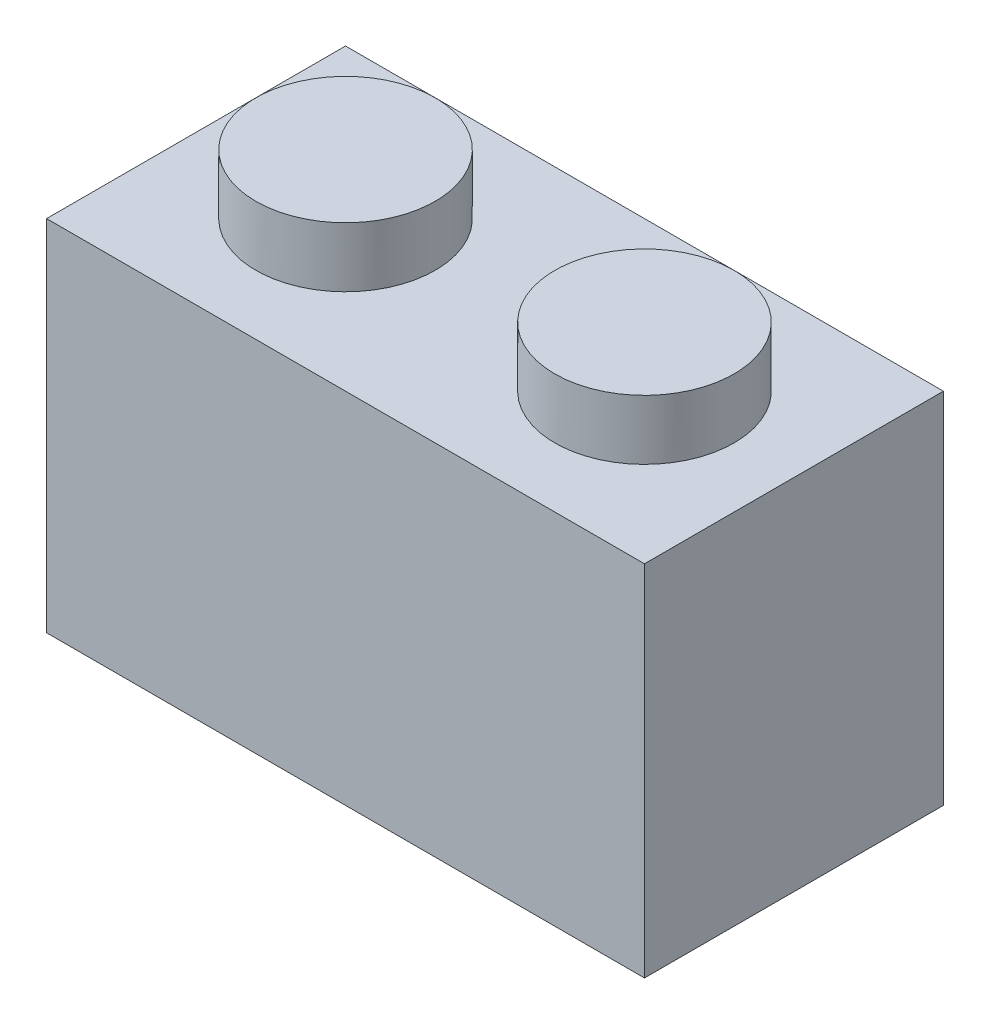
from build123d import *

# Parameters (mm, degrees)
SKETCH1_R             = 1.5
BOSS_EXTRUDE1_DEPTH   = 2
BOSS_EXTRUDE1_2_DEPTH = 2
SKETCH1_3_W           = 10
SKETCH1_3_H           = 5
BOSS_EXTRUDE2_DEPTH   = 1
SKETCH1_4_R           = 0.75
CUT_EXTRUDE1_DEPTH    = 1
SKETCH1_5_W           = 10
SKETCH1_5_H           = 5
SKETCH1_5_W_2         = 8
SKETCH1_5_H_2         = 3
SKETCH1_5_R           = 1
BOSS_EXTRUDE3_DEPTH   = 5


with BuildPart() as part:
    # Sketch1 → Boss-Extrude1 (new body)
    with BuildSketch(Plane(origin=(0, 0, 0), x_dir=(1, 0, 0), z_dir=(0, 1, 0))):
        with Locations((-2.5, 0)):
            Circle(SKETCH1_R)
    extrude(amount=BOSS_EXTRUDE1_DEPTH)



with BuildPart() as body_2:
    # Sketch1 → Boss-Extrude1 2 (new body)
    with BuildSketch(Plane(origin=(0, 0, 0), x_dir=(1, 0, 0), z_dir=(0, 1, 0))):
        with Locations((2.5, 0)):
            Circle(SKETCH1_R)
    extrude(amount=BOSS_EXTRUDE1_2_DEPTH)


with BuildPart() as part_1:
    add(part.part)

    add(body_2.part)  # Boss-Extrude2 merges body 2
    # Sketch1_3 → Boss-Extrude2 (add)
    with BuildSketch(Plane(origin=(0, 0, 0), x_dir=(1, 0, 0), z_dir=(0, 1, 0))):
        Rectangle(SKETCH1_3_W, SKETCH1_3_H)
    extrude(amount=BOSS_EXTRUDE2_DEPTH)

    # Sketch1_4 → Cut-Extrude1 (cut)
    with BuildSketch(Plane(origin=(0, 0, 0), x_dir=(1, 0, 0), z_dir=(0, 1, 0))):
        with Locations((-2.5, 0)):
            Circle(SKETCH1_4_R)
        with Locations((2.5, 0)):
            Circle(SKETCH1_4_R)
    extrude(amount=CUT_EXTRUDE1_DEPTH, mode=Mode.SUBTRACT)

    # Sketch1_5 → Boss-Extrude3 (add)
    # profile 1 of 2: a face of its own
    with BuildSketch(Plane(origin=(0, 0, 0), x_dir=(1, 0, 0), z_dir=(0, 1, 0))):
        Rectangle(SKETCH1_5_W, SKETCH1_5_H)
        Rectangle(SKETCH1_5_W_2, SKETCH1_5_H_2, mode=Mode.SUBTRACT)
    # profile 2 of 2: a face of its own
    with BuildSketch(Plane(origin=(0, 0, 0), x_dir=(1, 0, 0), z_dir=(0, 1, 0))):
        Circle(SKETCH1_5_R)
    extrude(amount=-BOSS_EXTRUDE3_DEPTH)


solid = part_1.part
